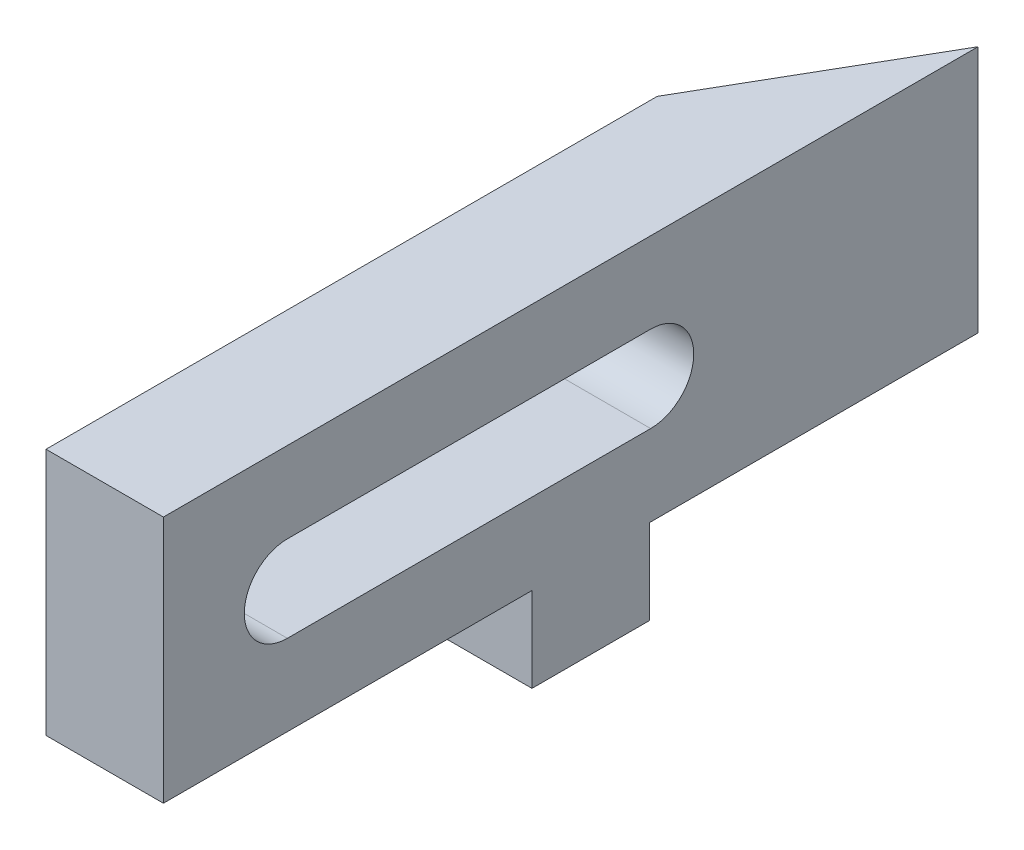
from build123d import *

# Parameters (mm, degrees)
BOSS_EXTRUDE1_DEPTH = 19
CUT_EXTRUDE1_DEPTH  = 10
SKETCH4_W           = 9
SKETCH4_H           = 9
BOSS_EXTRUDE2_DEPTH = 6.5


with BuildPart() as part:
    # Sketch1 → Boss-Extrude1 (new body)
    with BuildSketch(Plane(origin=(0, 0, 0), x_dir=(1, 0, 0), z_dir=(0, 1, 0))):
        Polygon((15.5, 26.846787517), (15.5, -20), (24.5, -20), (24.5, 42.435244785), align=None)
    extrude(amount=BOSS_EXTRUDE1_DEPTH)

    # Sketch3 → Cut-Extrude1 (cut, through all)
    with BuildSketch(Plane.ZY.offset(-15.5)):
        with BuildLine():
            Line((-17.346787517, 12.8), (10.5, 12.8))
            ThreePointArc((10.5, 12.8), (13.8, 9.5), (10.5, 6.2))
            Line((10.5, 6.2), (-17.346787517, 6.2))
            ThreePointArc((-17.346787517, 6.2), (-20.646787517, 9.5), (-17.346787517, 12.8))
        make_face()
    extrude(amount=-CUT_EXTRUDE1_DEPTH, mode=Mode.SUBTRACT)

    # Sketch4 → Boss-Extrude2 (add)
    with BuildSketch(Plane.XZ):
        with Locations((20, -12.75)):
            Rectangle(SKETCH4_W, SKETCH4_H)
    extrude(amount=BOSS_EXTRUDE2_DEPTH)


solid = part.part
